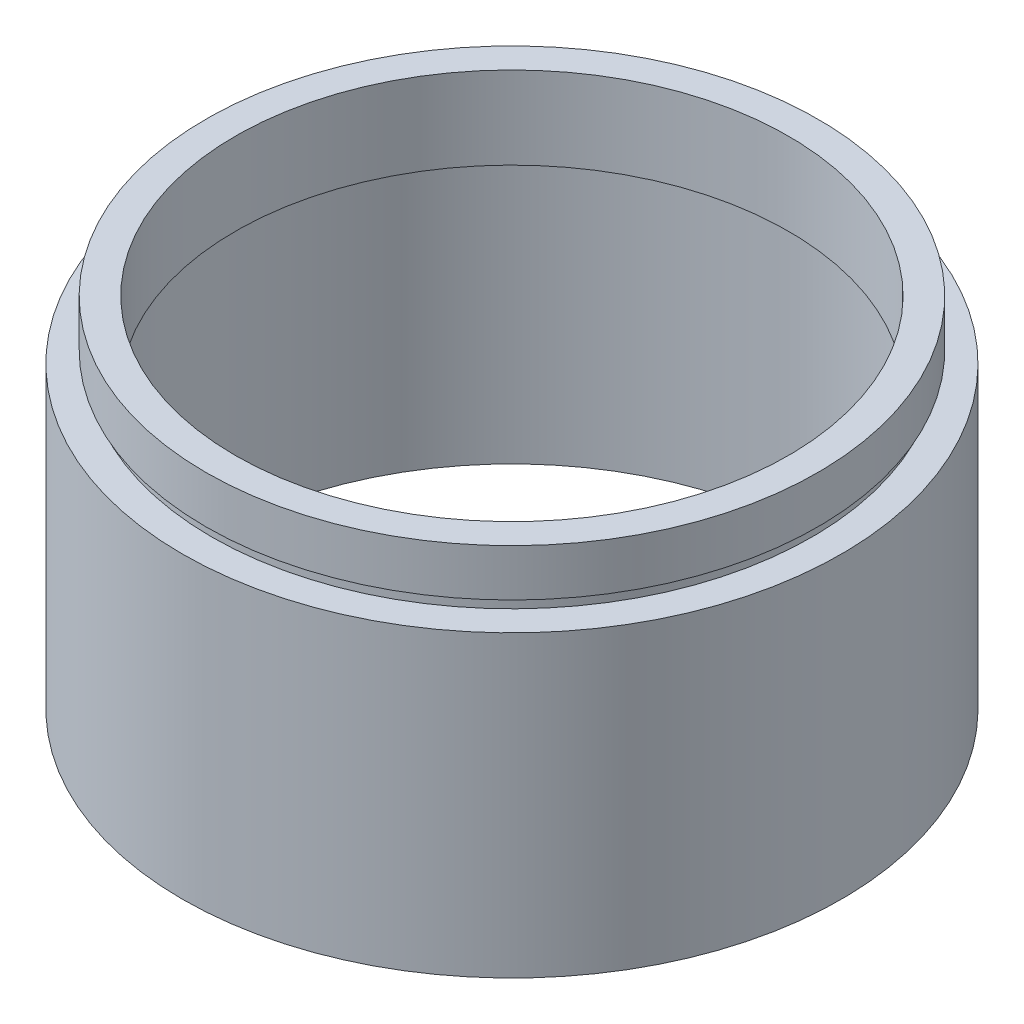
from build123d import *


with BuildPart() as part:
    # 草图1 → 旋转1 (revolve)
    with BuildSketch(Plane.XY, mode=Mode.PRIVATE) as revolve_1_sk:
        Polygon((23.5, 30.4), (26, 30.4), (26, 26.4), (25.5, 26.4), (25.5, 25.4), (28, 25.4), (28, 0), (25.5, 0), (25.5, 22.4), (26.1, 22.4), (26.1, 23.4), (23.5, 23.4), align=None)
    revolve(revolve_1_sk.sketch.rotate(Axis((0, 161.376166943, 0), (0, -1, 0)), 90), axis=Axis((0, 161.376166943, 0), (0, -1, 0)))  # turned: the seam where the file's is


solid = part.part
